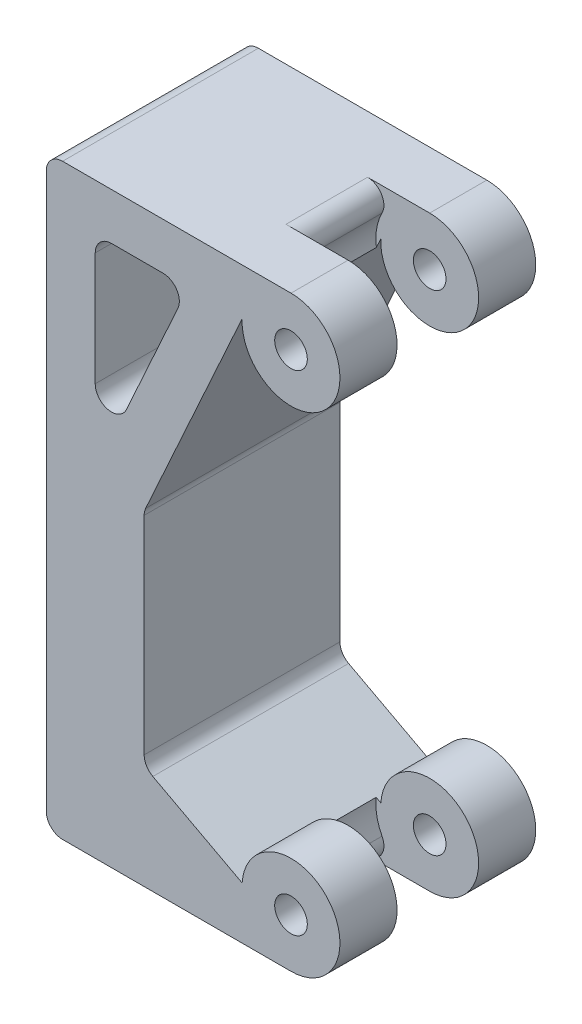
from build123d import *

# Parameters (mm, degrees)
SKETCH1_R               = 1
BOSS_EXTRUDE1_DEPTH     = 12
SKETCH2_R               = 3.3
CUT_EXTRUDE1_DEPTH      = 2.5
CUT_EXTRUDE1_DEPTH_BACK = 2.5
FILLET1_R               = 1
FILLET2_R               = 1
FILLET3_R               = 1
FILLET4_R               = 1


with BuildPart() as part:
    # Sketch1 → Boss-Extrude1 (new body)
    with BuildSketch(Plane.XY):
        with BuildLine():
            Line((0, 0), (15, 0))
            ThreePointArc((15, 0), (17.189317787, 5.051069873), (12.006370829, 3.19540825))
            Line((12.006370829, 3.19540825), (6, 6.391648207))
            Line((6, 6.391648207), (6, 19.92058514))
            Line((6, 19.92058514), (12.003141677, 33.137259573))
            ThreePointArc((12.003141677, 33.137259573), (17.072223598, 30.830693807), (15, 36))
            Line((15, 36), (0, 36))
            Line((0, 36), (0, 0))
        make_face()
        with Locations((15, 33)):
            Circle(SKETCH1_R, mode=Mode.SUBTRACT)
        with Locations((15, 3)):
            Circle(SKETCH1_R, mode=Mode.SUBTRACT)
        Polygon((8.708182188, 33.137259573), (3, 33.137259573), (3, 20.569975699), align=None, mode=Mode.SUBTRACT)
    extrude(amount=BOSS_EXTRUDE1_DEPTH)

    # Sketch2 → Cut-Extrude1 (cut, two sides)
    with BuildSketch(Plane.XY.offset(6)) as cut_extrude1_sk:
        with Locations((15, 33)):
            Circle(SKETCH2_R)
        with Locations((15, 3)):
            Circle(SKETCH2_R)
    extrude(amount=CUT_EXTRUDE1_DEPTH, mode=Mode.SUBTRACT)
    extrude(cut_extrude1_sk.sketch, amount=-CUT_EXTRUDE1_DEPTH_BACK, mode=Mode.SUBTRACT)

    # Fillet1
    fillet1_edges = [part.edges().sort_by_distance(p)[0] for p in [
        (0, 36, 6),
        (0, 0, 6),
    ]]
    fillet(fillet1_edges, radius=FILLET1_R)

    # Fillet2
    fillet2_edges = [part.edges().sort_by_distance(p)[0] for p in [
        (6, 19.92058514, 6),
        (6, 6.391648207, 6),
    ]]
    fillet(fillet2_edges, radius=FILLET2_R)

    # Fillet3
    fillet3_edges = [part.edges().sort_by_distance(p)[0] for p in [
        (13.625227292, 36, 6),
        (13.625227292, 0, 6),
    ]]
    fillet(fillet3_edges, radius=FILLET3_R)

    # Fillet4
    fillet4_edges = [part.edges().sort_by_distance(p)[0] for p in [
        (3, 20.569975699, 6),
        (8.708182188, 33.137259573, 6),
        (3, 33.137259573, 6),
    ]]
    fillet(fillet4_edges, radius=FILLET4_R)


solid = part.part
